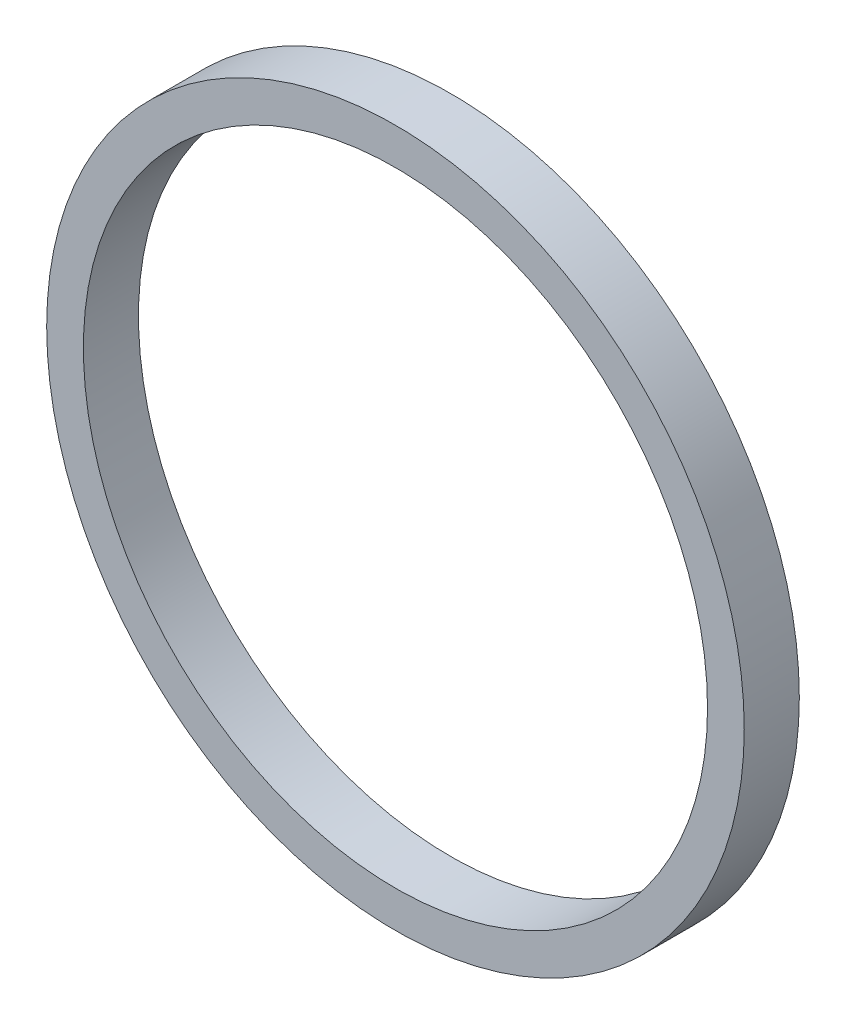
from build123d import *

# Parameters (mm, degrees)
SKETCH_1_R      = 9.5
SKETCH_1_R_2    = 8.5
EXTRUDE_1_DEPTH = 1.5


with BuildPart() as part:
    # Эскиз1 → Бобышка-Вытянуть1 (new body)
    with BuildSketch(Plane.XY):
        Circle(SKETCH_1_R)
        Circle(SKETCH_1_R_2, mode=Mode.SUBTRACT)
    extrude(amount=EXTRUDE_1_DEPTH)


solid = part.part
